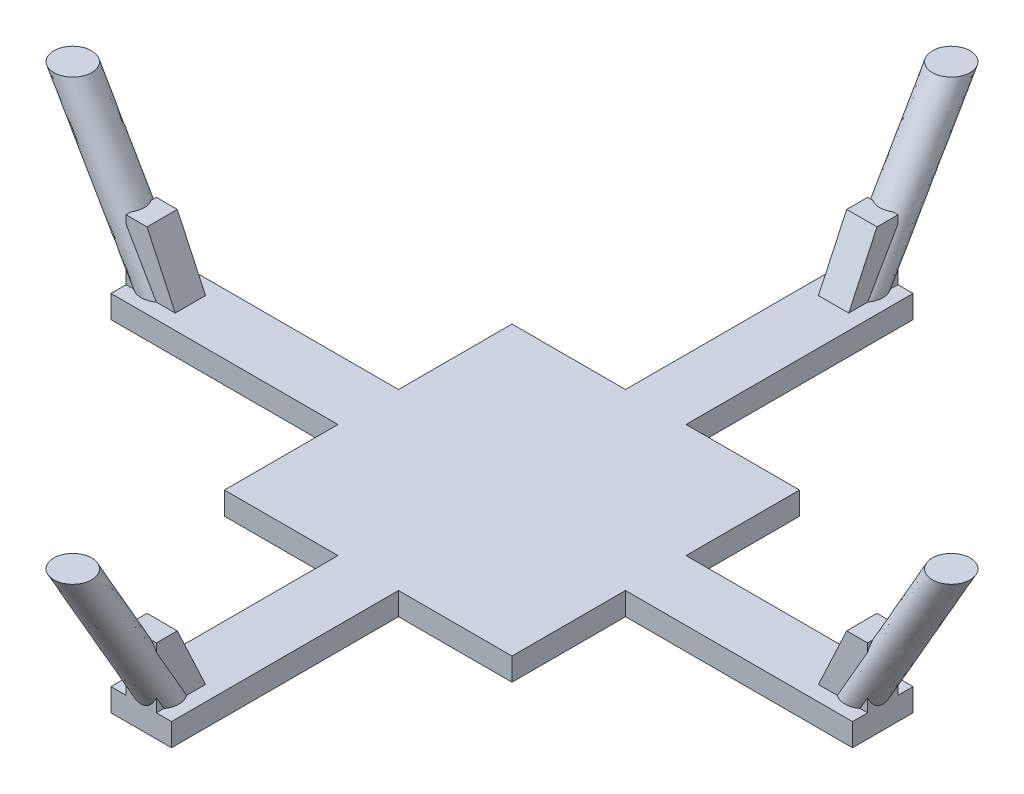
from build123d import *

# Parameters (mm, degrees)
SKETCH1_W           = 38
SKETCH1_H           = 38
BOSS_EXTRUDE1_DEPTH = 3
SKETCH2_W           = 30
SKETCH2_H           = 8
BOSS_EXTRUDE2_DEPTH = 3
SKETCH8_R           = 2.5
BOSS_EXTRUDE5_DEPTH = 2
CIRPATTERN1_COUNT   = 4


with BuildPart() as part:
    # Sketch1 → Boss-Extrude1 (new body)
    with BuildSketch(Plane(origin=(0, 0, 0), x_dir=(1, 0, 0), z_dir=(0, 1, 0))):
        Rectangle(SKETCH1_W, SKETCH1_H)
    extrude(amount=BOSS_EXTRUDE1_DEPTH)

    # Sketch2 → Boss-Extrude2 (add)
    with BuildSketch(Plane(origin=(0, 0, 0), x_dir=(1, 0, 0), z_dir=(0, 1, 0))):
        with Locations((-34, 0)):
            Rectangle(SKETCH2_W, SKETCH2_H)
    boss_extrude2 = extrude(amount=BOSS_EXTRUDE2_DEPTH)

    # Sweep1: sweep along a path in Sketch7
    with BuildLine(Plane.XY) as sweep1_path:
        Line((-46.5, 3), (-58.047005384, 23))
    # Sketch8 → Sweep1 (sweep)
    with BuildSketch(Plane(origin=(0, 3, 0), x_dir=(1, 0, 0), z_dir=(0, 1, 0))):
        with Locations((-46.5, 0)):
            Circle(SKETCH8_R)
    sweep1 = sweep(path=sweep1_path.line)

    # Sketch6 → Boss-Extrude5 (add, symmetric)
    with BuildSketch(Plane.XY):
        Polygon((-46.230461265, 11), (-42.5, 3), (-46.5, 3), (-49, 3), (-49, 11), align=None)
    boss_extrude5 = extrude(amount=BOSS_EXTRUDE5_DEPTH, both=True)

    # CirPattern1: Boss-Extrude2, Sweep1, Boss-Extrude5 ×4 about axis
    cirpattern1_axis = Axis((0, 0, 0), (0, 1, 0))
    for i in range(1, CIRPATTERN1_COUNT):
        add(boss_extrude2.rotate(cirpattern1_axis, i * 360 / CIRPATTERN1_COUNT))
        add(sweep1.rotate(cirpattern1_axis, i * 360 / CIRPATTERN1_COUNT))
        add(boss_extrude5.rotate(cirpattern1_axis, i * 360 / CIRPATTERN1_COUNT))


solid = part.part
